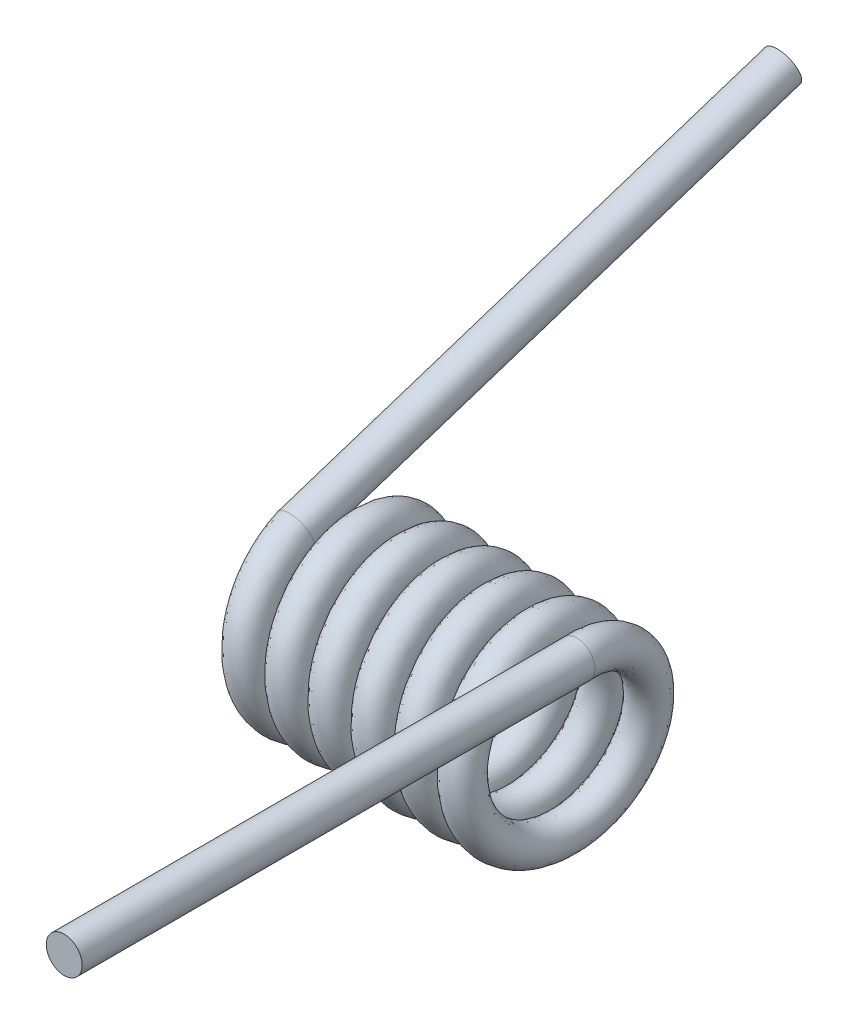
from build123d import *

# Parameters (mm, degrees)
SPRING_MAIN_COIL_PITCH       = 1.067226891
SPRING_MAIN_COIL_HEIGHT      = 6.35
SPRING_MAIN_COIL_RADIUS      = 2.032
SPRING_MAIN_COIL_START_ANGLE = -90
SKETCH2_R                    = 0.4445
SKETCH3_R                    = 0.4445
FRONT_LEG_DEPTH              = 12.7
SKETCH4_R                    = 0.4445
REAR_LEG_DEPTH               = 12.7


with BuildPart() as part:
    # spring main coil: sweep along a helix
    with BuildLine() as spring_main_coil_path:
        add(Helix(SPRING_MAIN_COIL_PITCH, SPRING_MAIN_COIL_HEIGHT, SPRING_MAIN_COIL_RADIUS, center=(0, 0, 0), direction=(-1, 0, 0), mode=Mode.PRIVATE).rotate(Axis((0, 0, 0), (-1, 0, 0)), SPRING_MAIN_COIL_START_ANGLE))
    # Sketch2 → spring main coil (sweep)
    with BuildSketch(Plane.XY):
        with Locations((0, 2.032)):
            Circle(SKETCH2_R)
    sweep(path=spring_main_coil_path.line, is_frenet=True)

    # Sketch3 → front leg (add)
    with BuildSketch(Plane.XY):
        with Locations((0, 2.032)):
            Circle(SKETCH3_R)
    extrude(amount=FRONT_LEG_DEPTH)

    # Sketch4 → rear leg (add)
    with BuildSketch(Plane(origin=(0, 0, 0), x_dir=(-1, 0, 0), z_dir=(0, 0.309030308, -0.95105219))):
        with Locations((6.350332643, 2.032)):
            Circle(SKETCH4_R)
    extrude(amount=REAR_LEG_DEPTH)


solid = part.part
